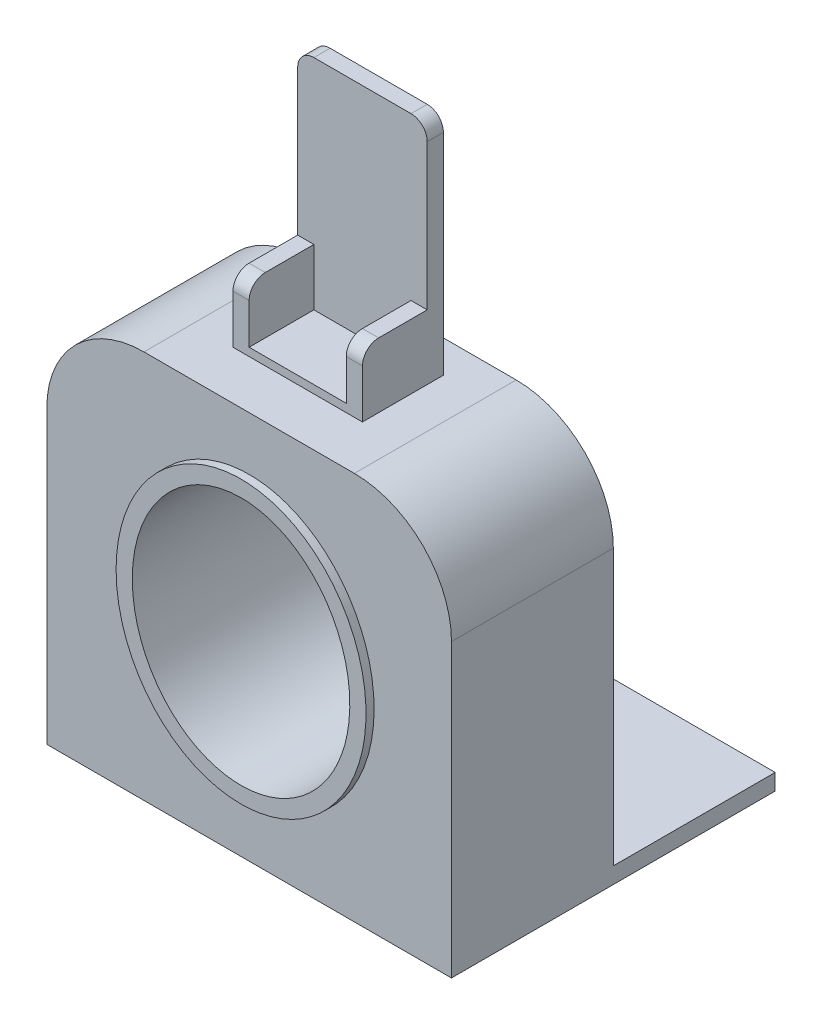
from build123d import *

# Parameters (mm, degrees)
CROQUIS1_W              = 250
CROQUIS1_H              = 100
SALIENTE_EXTRUIR1_DEPTH = 240
CROQUIS1_3_W            = 250
CROQUIS1_3_H            = 100
SALIENTE_EXTRUIR2_DEPTH = 10
REDONDEO2_R             = 60
CROQUIS7_RX             = 76.972297538
CROQUIS7_RY             = 67.204239475
CORTAR_EXTRUIR4_DEPTH   = 143
CROQUIS8_RX             = 76.972297538
CROQUIS8_RY             = 67.204239475
SALIENTE_EXTRUIR3_DEPTH = 5
SALIENTE_EXTRUIR4_DEPTH = 140
CROQUIS10_4_W           = 60
CROQUIS10_4_H           = 40
SALIENTE_EXTRUIR5_DEPTH = 5
CROQUIS10_7_W           = 10
CROQUIS10_7_H           = 40
SALIENTE_EXTRUIR6_DEPTH = 40
REDONDEO3_R             = 10


with BuildPart() as part:
    # Croquis1 → Saliente-Extruir1 (new body)
    with BuildSketch(Plane(origin=(0, 0, 0), x_dir=(1, 0, 0), z_dir=(0, 1, 0))):
        with Locations((125, 50)):
            Rectangle(CROQUIS1_W, CROQUIS1_H)
    extrude(amount=SALIENTE_EXTRUIR1_DEPTH)

    # Croquis1_3 → Saliente-Extruir2 (add)
    with BuildSketch(Plane(origin=(0, 0, 0), x_dir=(1, 0, 0), z_dir=(0, 1, 0))):
        with Locations((125, 150)):
            Rectangle(CROQUIS1_3_W, CROQUIS1_3_H)
    extrude(amount=SALIENTE_EXTRUIR2_DEPTH)

    # Redondeo2
    redondeo2_edges = [part.edges().sort_by_distance(p)[0] for p in [
        (0, 240, -50),
        (250, 240, -50),
    ]]
    fillet(redondeo2_edges, radius=REDONDEO2_R)

    # Croquis7 → Cortar-Extruir4 (cut)
    with BuildSketch(Plane.XY):
        with Locations(Location((125, 120), (0, 0, 90))):
            Ellipse(CROQUIS7_RX, CROQUIS7_RY)
    extrude(amount=-CORTAR_EXTRUIR4_DEPTH, mode=Mode.SUBTRACT)

    # Croquis8 → Saliente-Extruir3 (add)
    with BuildSketch(Plane.XY):
        with BuildLine():
            add(Edge.make_bspline(
                [(125, 33.027702462), (127.716922997, 33.027702462), (130.404614336, 33.188438016), (135.724227666, 33.816566957), (138.356140016, 34.284013351), (143.564938997, 35.521474998), (146.141826175, 36.291487238), (149.32789788, 37.44666128), (149.963373673, 37.687404872), (151.222655871, 38.185011316), (151.847502015, 38.442239729), (153.70789977, 39.238771481), (154.929321189, 39.80290291), (158.538604748, 41.591903506), (160.871628277, 42.913129324), (165.395861295, 45.804761696), (167.58815404, 47.376066564), (171.826538699, 50.764218527), (173.840461698, 52.555062734), (177.671334874, 56.317817281), (179.488232347, 58.289776068), (182.931848653, 62.408514262), (184.558548159, 64.555311436), (186.856901598, 67.905760262), (187.596747198, 69.04071402), (189.017296342, 71.333449758), (189.6993083, 72.493124445), (192.971944449, 78.356200717), (195.154024171, 83.251956302), (197.358832322, 89.617795434), (197.773446154, 90.903439911), (198.549527035, 93.499465527), (198.90845874, 94.801347136), (199.900213511, 98.718294557), (200.448185039, 101.344637868), (201.763342829, 109.267362405), (202.204539447, 114.607070459), (202.204164292, 121.355053919), (202.176088659, 122.711265866), (202.064301478, 125.410452751), (201.980723301, 126.754629699), (201.648104971, 130.771139961), (201.317354659, 133.427486666), (200.000943496, 141.333104769), (198.694169349, 146.519550286), (196.490505918, 152.89104827), (196.019747164, 154.162853647), (195.025553036, 156.678150817), (194.502863938, 157.920234824), (192.858566532, 161.600125171), (191.660898436, 163.991673425), (187.761672007, 170.980079827), (184.75725411, 175.392744669), (180.875974654, 180.052106022), (180.437687128, 180.565534743), (179.546751621, 181.583658434), (179.09337423, 182.089135096), (177.717535309, 183.585353779), (176.779803074, 184.555633176), (173.905444326, 187.385345487), (171.907805387, 189.163850968), (167.748045081, 192.502690959), (165.585944795, 194.06305343), (161.090554052, 196.95671019), (158.757317239, 198.290075632), (155.72577479, 199.804250133), (155.112808717, 200.099822067), (153.88335661, 200.671549412), (153.266110917, 200.948114377), (151.406864587, 201.750096433), (150.157359681, 202.247819081), (146.379036893, 203.630980583), (143.820490433, 204.406706354), (138.623300542, 205.662560658), (135.98466882, 206.142732406), (132.634166248, 206.550255722), (131.96144789, 206.622099252), (130.610691005, 206.746152274), (129.93172719, 206.798392098), (127.900475049, 206.924426335), (126.55019563, 206.968001148), (122.510773219, 206.97998383), (119.833015326, 206.829969745), (114.507334656, 206.219611994), (111.859412215, 205.759264851), (107.910237087, 204.832541616), (106.593459447, 204.482838697), (103.994656921, 203.711410555), (102.711704261, 203.289784981), (98.91073308, 201.920359147), (96.440473583, 200.868288733), (91.623019608, 198.495465534), (89.275838057, 197.174684523), (85.847080779, 194.992620648), (84.71874619, 194.230876818), (82.517429794, 192.658127473), (81.441211058, 191.845169128), (78.283535549, 189.32908586), (76.27287878, 187.548949253), (72.432879578, 183.791453982), (70.603560889, 181.814069491), (67.99406522, 178.7017115), (67.145842384, 177.638458972), (65.509882594, 175.484104304), (64.72007818, 174.390671655), (62.432585129, 171.063111394), (61.016620532, 168.781834632), (58.394106502, 164.098462965), (57.187582612, 161.696353323), (55.532932124, 158.003686436), (55.007282323, 156.757854747), (54.007986074, 154.236189011), (53.536955939, 152.966840124), (51.326504906, 146.593244825), (50.011292376, 141.394042449), (48.68568488, 133.451947581), (48.35242998, 130.780535642), (48.017922664, 126.736804027), (47.934071147, 125.381056898), (47.82305979, 122.680583454), (47.7956054, 121.333200704), (47.79638432, 114.610332415), (48.235235275, 109.276623608), (49.552019564, 101.343057777), (50.101380969, 98.70977145), (51.097892129, 94.777389169), (51.459613379, 93.467418163), (52.234572443, 90.878122589), (52.64839956, 89.596085706), (54.84833069, 83.248504751), (57.023259968, 78.369066466), (60.932315801, 71.359424739), (62.343788817, 69.074787684), (64.633950857, 65.730613408), (65.428738625, 64.626504273), (67.06308957, 62.467122017), (67.902663487, 61.411404642), (70.488298836, 58.315872226), (72.301112731, 56.347504426), (76.107190252, 52.603909795), (78.100429201, 50.828656551), (82.275122661, 47.479603046), (84.456517338, 45.90573874), (87.309903664, 44.073958286), (87.887913061, 43.71382706), (89.049899878, 43.011672104), (89.634271423, 42.669355361), (91.39746439, 41.668541908), (92.5863576, 41.036165001), (96.193121975, 39.24298859), (98.65097198, 38.185868736), (103.674761223, 36.35194367), (106.240682844, 35.57509277), (110.174376905, 34.629763782), (111.499773132, 34.351388781), (114.179927084, 33.870783809), (115.524400715, 33.670430265), (118.219575281, 33.349651967), (119.570693495, 33.229152241), (121.602683565, 33.108421489), (122.280899507, 33.078186262), (123.639111575, 33.03782677), (124.320769251, 33.027702462), (125, 33.027702462)],
                knots=[0, 0, 0, 0, 0.015625, 0.015625, 0.03125, 0.03125, 0.046875, 0.046875, 0.05078125, 0.05078125, 0.0546875, 0.0546875, 0.0625, 0.0625, 0.078125, 0.078125, 0.09375, 0.09375, 0.109375, 0.109375, 0.125, 0.125, 0.140625, 0.140625, 0.1484375, 0.1484375, 0.15625, 0.15625, 0.1875, 0.1875, 0.1953125, 0.1953125, 0.203125, 0.203125, 0.21875, 0.21875, 0.25, 0.25, 0.2578125, 0.2578125, 0.265625, 0.265625, 0.28125, 0.28125, 0.3125, 0.3125, 0.3203125, 0.3203125, 0.328125, 0.328125, 0.34375, 0.34375, 0.375, 0.375, 0.37890625, 0.37890625, 0.3828125, 0.3828125, 0.390625, 0.390625, 0.40625, 0.40625, 0.421875, 0.421875, 0.4375, 0.4375, 0.44140625, 0.44140625, 0.4453125, 0.4453125, 0.453125, 0.453125, 0.46875, 0.46875, 0.484375, 0.484375, 0.48828125, 0.48828125, 0.4921875, 0.4921875, 0.5, 0.5, 0.515625, 0.515625, 0.53125, 0.53125, 0.5390625, 0.5390625, 0.546875, 0.546875, 0.5625, 0.5625, 0.578125, 0.578125, 0.5859375, 0.5859375, 0.59375, 0.59375, 0.609375, 0.609375, 0.625, 0.625, 0.6328125, 0.6328125, 0.640625, 0.640625, 0.65625, 0.65625, 0.671875, 0.671875, 0.6796875, 0.6796875, 0.6875, 0.6875, 0.71875, 0.71875, 0.734375, 0.734375, 0.7421875, 0.7421875, 0.75, 0.75, 0.78125, 0.78125, 0.796875, 0.796875, 0.8046875, 0.8046875, 0.8125, 0.8125, 0.84375, 0.84375, 0.859375, 0.859375, 0.8671875, 0.8671875, 0.875, 0.875, 0.890625, 0.890625, 0.90625, 0.90625, 0.921875, 0.921875, 0.92578125, 0.92578125, 0.9296875, 0.9296875, 0.9375, 0.9375, 0.953125, 0.953125, 0.96875, 0.96875, 0.9765625, 0.9765625, 0.984375, 0.984375, 0.9921875, 0.9921875, 0.99609375, 0.99609375, 1, 1, 1, 1], degree=3))
        make_face()
        with Locations(Location((125, 120), (0, 0, 90))):
            Ellipse(CROQUIS8_RX, CROQUIS8_RY, mode=Mode.SUBTRACT)
    extrude(amount=SALIENTE_EXTRUIR3_DEPTH)

    # Croquis10 → Saliente-Extruir4 (add)
    with BuildSketch(Plane(origin=(0, 240, 0), x_dir=(1, 0, 0), z_dir=(0, 1, 0))):
        Polygon((85, 80), (85, 70), (95, 70), (155, 70), (165, 70), (165, 80), align=None)
    extrude(amount=SALIENTE_EXTRUIR4_DEPTH)

    # Croquis10_4 → Saliente-Extruir5 (add)
    with BuildSketch(Plane(origin=(0, 240, 0), x_dir=(1, 0, 0), z_dir=(0, 1, 0))):
        with Locations((125, 50)):
            Rectangle(CROQUIS10_4_W, CROQUIS10_4_H)
    extrude(amount=SALIENTE_EXTRUIR5_DEPTH)

    # Croquis10_7 → Saliente-Extruir6 (add)
    with BuildSketch(Plane(origin=(0, 240, 0), x_dir=(1, 0, 0), z_dir=(0, 1, 0))):
        with Locations((90, 50)):
            Rectangle(CROQUIS10_7_W, CROQUIS10_7_H)
        with Locations((160, 50)):
            Rectangle(CROQUIS10_7_W, CROQUIS10_7_H)
    extrude(amount=SALIENTE_EXTRUIR6_DEPTH)

    # Redondeo3
    redondeo3_edges = [part.edges().sort_by_distance(p)[0] for p in [
        (90, 280, -30),
        (160, 280, -30),
        (85, 380, -75),
        (165, 380, -75),
    ]]
    fillet(redondeo3_edges, radius=REDONDEO3_R)


solid = part.part
